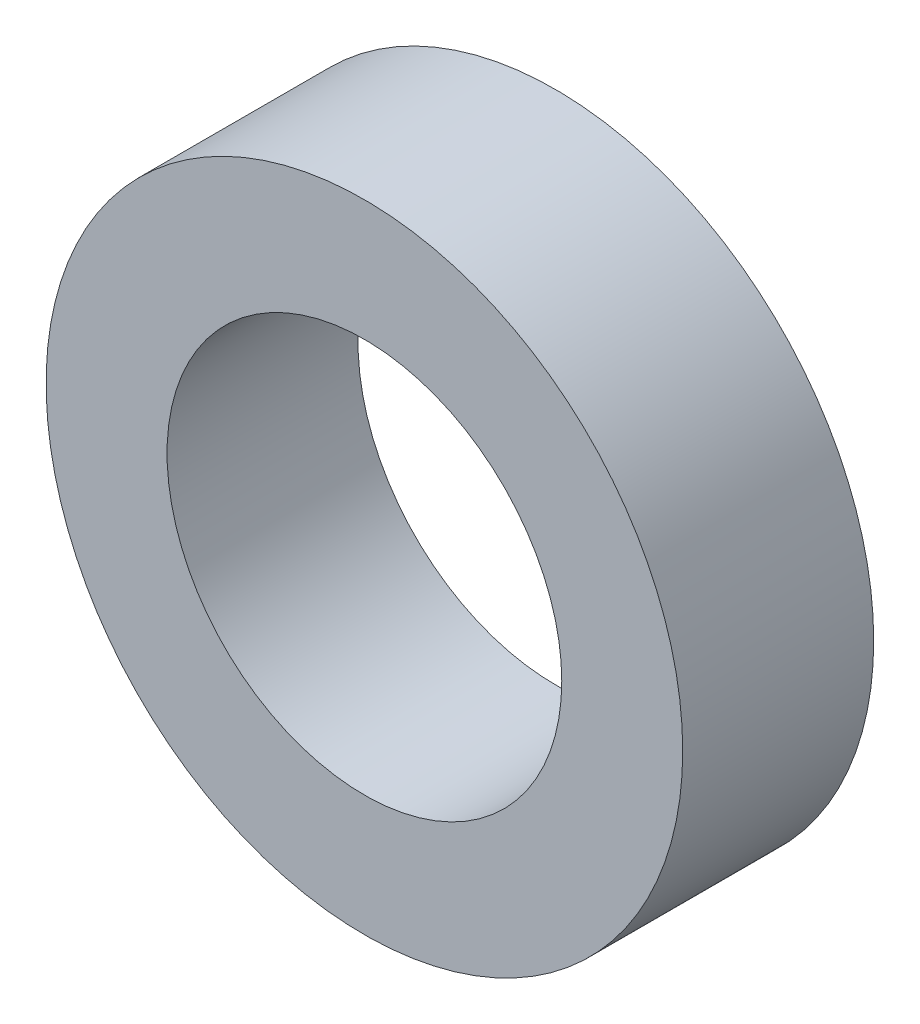
from build123d import *

# Parameters (mm, degrees)
SKETCH_1_R      = 5
SKETCH_1_R_2    = 3.1
EXTRUDE_3_DEPTH = 3


with BuildPart() as part:
    # ｽｹｯﾁ1 → ﾎﾞｽ - 押し出し3 (new body)
    with BuildSketch(Plane.XY):
        Circle(SKETCH_1_R)
        Circle(SKETCH_1_R_2, mode=Mode.SUBTRACT)
    extrude(amount=EXTRUDE_3_DEPTH)


solid = part.part
